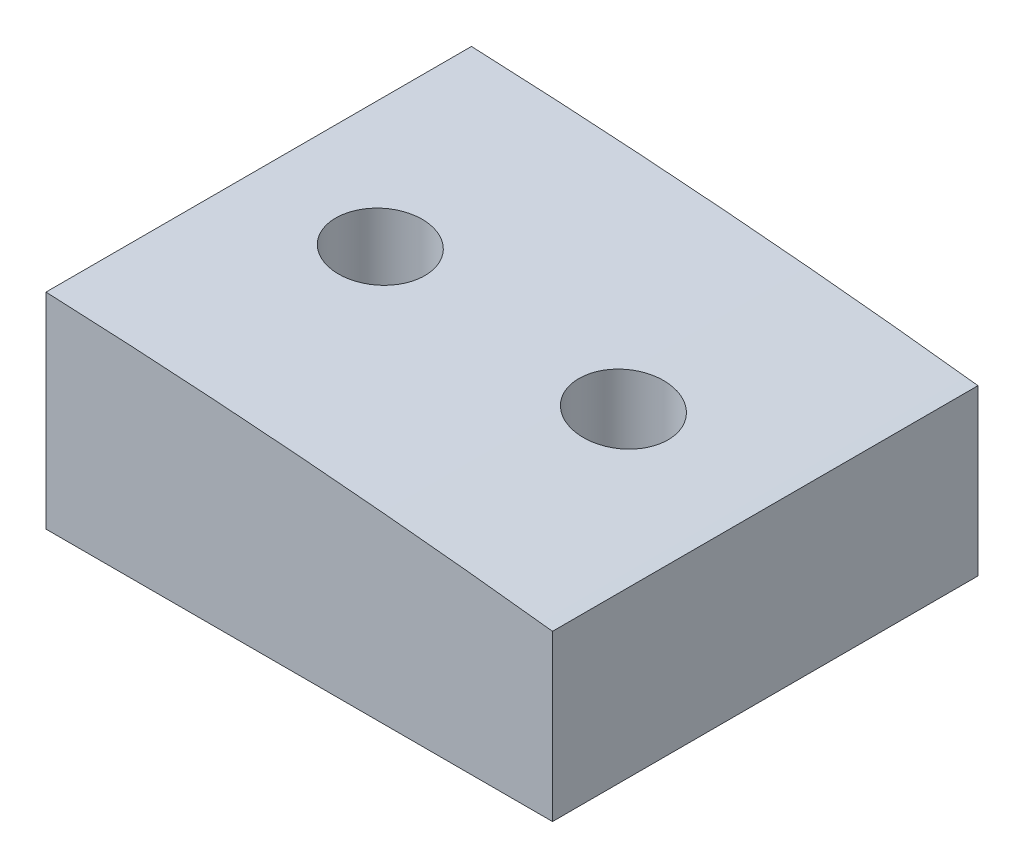
from build123d import *

# Parameters (mm, degrees)
BOSS_EXTRU_1_DEPTH = 15.75
D_GAGEMENT_M61_D   = 6.6


with BuildPart() as part:
    # Esquisse1 → Boss.-Extru.1 (new body, symmetric)
    with BuildSketch(Plane.XY):
        with BuildLine():
            Line((0, 0), (37.5, 0))
            Line((37.5, 0), (37.5, 12.2))
            ThreePointArc((37.5, 12.2), (18.778224846, 14.052810579), (0, 15.2))
            Line((0, 15.2), (0, 0))
        make_face()
    extrude(amount=BOSS_EXTRU_1_DEPTH, both=True)

    # Dégagement M61 (through all)
    with Locations(Plane(origin=(0, 0, 0), x_dir=(-1, 0, 0), z_dir=(0, -1, 0))):
        with Locations((-9, 0), (-27, 0)):
            Hole(D_GAGEMENT_M61_D / 2)


solid = part.part
